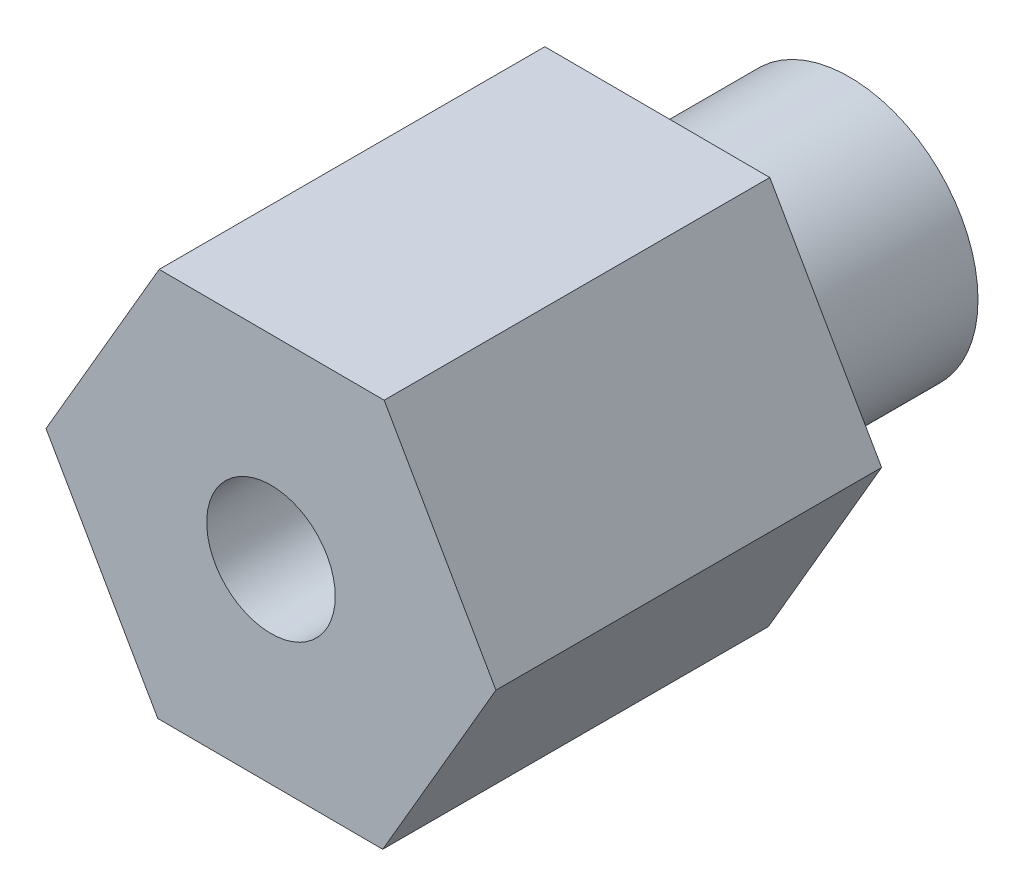
from build123d import *

# Parameters (mm, degrees)
SKETCH_1_R          = 2
EXTRUDE_1_DEPTH     = 3
EXTRUDE_2_DEPTH     = 6
SKETCH_3_R          = 1
CUT_EXTRUDE_1_DEPTH = 10


with BuildPart() as part:
    # 草图1 → 凸台-拉伸1 (new body)
    with BuildSketch(Plane.XY):
        Circle(SKETCH_1_R)
    extrude(amount=EXTRUDE_1_DEPTH)

    # 草图2 → 凸台-拉伸2 (add)
    with BuildSketch(Plane.XY.offset(3)):
        Polygon((1.760877545, 3.024782682), (-1.739099871, 3.037356028), (-3.499977416, 0.012573346), (-1.760877545, -3.024782682), (1.739099871, -3.037356028), (3.499977416, -0.012573346), align=None)
    extrude(amount=EXTRUDE_2_DEPTH)

    # 草图3 → 切除-拉伸1 (cut)
    with BuildSketch(Plane.XY.offset(9)):
        Circle(SKETCH_3_R)
    extrude(amount=-CUT_EXTRUDE_1_DEPTH, mode=Mode.SUBTRACT)


solid = part.part
